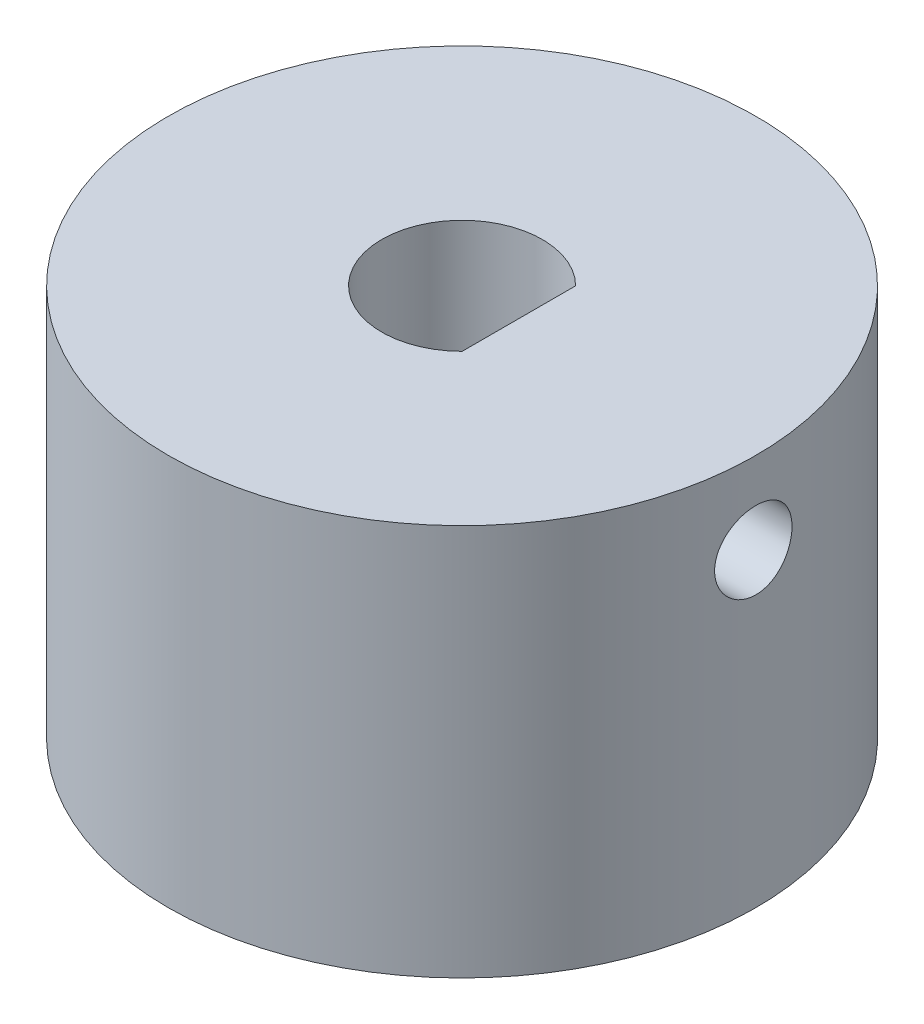
from build123d import *

# Parameters (mm, degrees)
SKETCH1_R           = 9.525
BOSS_EXTRUDE1_DEPTH = 6.35
CUT_EXTRUDE1_START  = -6.35
CUT_EXTRUDE1_DEPTH  = 6.35
CUT_EXTRUDE2_START  = -6.35
CUT_EXTRUDE2_DEPTH  = 6.35
SKETCH4_R           = 1.254125
CUT_EXTRUDE3_DEPTH  = 10.525
SKETCH4_3_R         = 1.254125
CUT_EXTRUDE4_DEPTH  = 10.5250001


with BuildPart() as part:
    # Sketch1 → Boss-Extrude1 (new body, symmetric)
    with BuildSketch(Plane(origin=(0, 0, 0), x_dir=(1, 0, 0), z_dir=(0, 1, 0))):
        Circle(SKETCH1_R)
    extrude(amount=BOSS_EXTRUDE1_DEPTH, both=True)

    # Sketch2 → Cut-Extrude1 (cut)
    with BuildSketch(Plane(origin=(0, 6.35, 0), x_dir=(1, 0, 0), z_dir=(0, 1, 0)).offset(CUT_EXTRUDE1_START)):
        with BuildLine():
            Line((1.8415, 1.840404847), (1.8415, -1.840404847))
            ThreePointArc((1.8415, -1.840404847), (-2.6035, 0), (1.8415, 1.840404847))
        make_face()
    extrude(amount=CUT_EXTRUDE1_DEPTH, mode=Mode.SUBTRACT)

    # Sketch3 → Cut-Extrude2 (cut)
    with BuildSketch(Plane.XZ.offset(6.35).offset(CUT_EXTRUDE2_START)):
        with BuildLine():
            Line((2.449999926, 3.224903191), (2.449999926, -3.224903191))
            ThreePointArc((2.449999926, -3.224903191), (-4.050000028, 0), (2.449999926, 3.224903191))
        make_face()
    extrude(amount=CUT_EXTRUDE2_DEPTH, mode=Mode.SUBTRACT)

    # Sketch4 → Cut-Extrude3 (cut, through all)
    with BuildSketch(Plane(origin=(0, 0, 0), x_dir=(0, 0, -1), z_dir=(1, 0, 0))):
        with Locations((0, -3.389153937)):
            Circle(SKETCH4_R)
    extrude(amount=-CUT_EXTRUDE3_DEPTH, mode=Mode.SUBTRACT)

    # Sketch4_3 → Cut-Extrude4 (cut, through all)
    with BuildSketch(Plane(origin=(0, 0, 0), x_dir=(0, 0, -1), z_dir=(1, 0, 0))):
        with Locations((0, 3.690412064)):
            Circle(SKETCH4_3_R)
    extrude(amount=CUT_EXTRUDE4_DEPTH, mode=Mode.SUBTRACT)


solid = part.part
